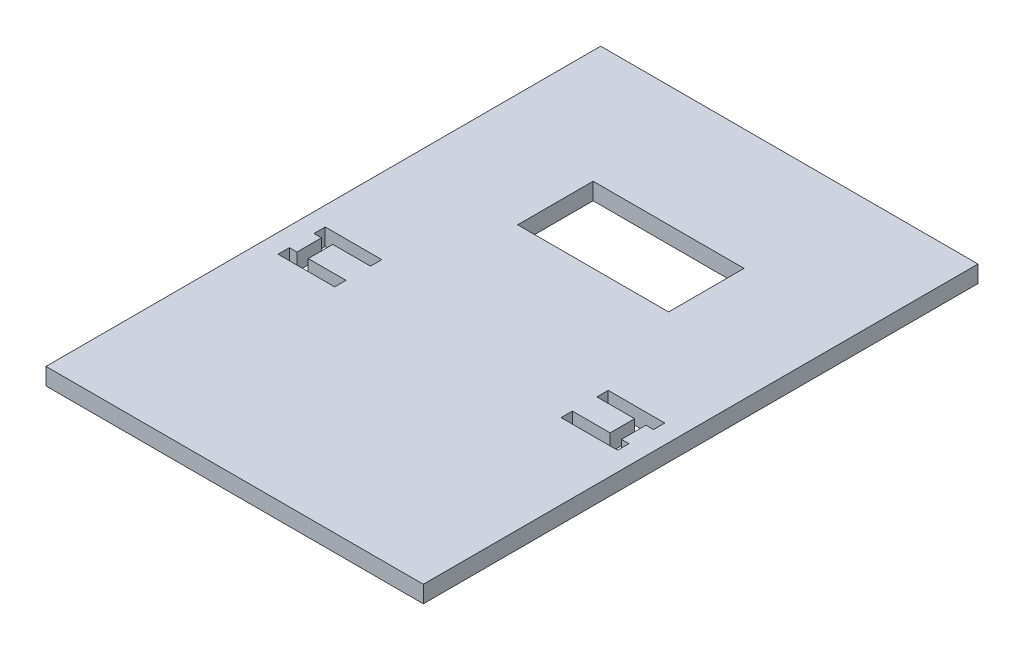
from build123d import *

# Parameters (mm, degrees)
SKETCH2_W           = 100
SKETCH2_H           = 147
SKETCH2_W_2         = 40
SKETCH2_H_2         = 20
BOSS_EXTRUDE1_DEPTH = 4.5


with BuildPart() as part:
    # Sketch2 → Boss-Extrude1 (new body)
    with BuildSketch(Plane(origin=(0, 0, 0), x_dir=(1, 0, 0), z_dir=(0, 1, 0))):
        with Locations((0, -2.47075608)):
            Rectangle(SKETCH2_W, SKETCH2_H)
        with Locations((0, 29.02924392)):
            Rectangle(SKETCH2_W_2, SKETCH2_H_2, mode=Mode.SUBTRACT)
        Polygon((-45, -6.97075608), (-30, -6.97075608), (-30, -9.97075608), (-40, -9.97075608), (-40, -16.47075608), (-30, -16.47075608), (-30, -19.47075608), (-45, -19.47075608), (-45, -16.47075608), (-43, -16.47075608), (-43, -9.97075608), (-45, -9.97075608), align=None, mode=Mode.SUBTRACT)
        Polygon((43, -9.97075608), (45, -9.97075608), (45, -6.97075608), (30, -6.97075608), (30, -9.97075608), (40, -9.97075608), (40, -16.47075608), (30, -16.47075608), (30, -19.47075608), (45, -19.47075608), (45, -16.47075608), (43, -16.47075608), align=None, mode=Mode.SUBTRACT)
    extrude(amount=BOSS_EXTRUDE1_DEPTH)


solid = part.part
